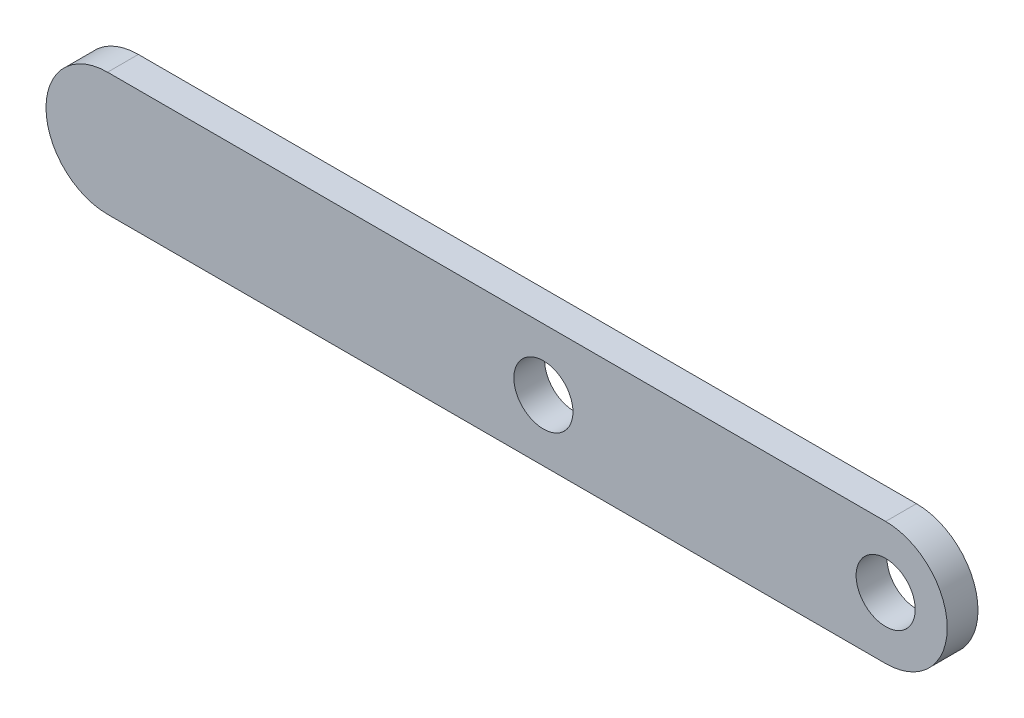
from build123d import *

# Parameters (mm, degrees)
SKETCH1_R           = 3.048
BOSS_EXTRUDE1_DEPTH = 3.175


with BuildPart() as part:
    # Sketch1 → Boss-Extrude1 (new body)
    with BuildSketch(Plane.XY):
        with BuildLine():
            Line((-40.132, -6.35), (40.132, -6.35))
            ThreePointArc((40.132, -6.35), (46.482, 0), (40.132, 6.35))
            Line((40.132, 6.35), (-40.132, 6.35))
            ThreePointArc((-40.132, 6.35), (-46.482, 0), (-40.132, -6.35))
        make_face()
        with Locations((40.132, 0)):
            Circle(SKETCH1_R, mode=Mode.SUBTRACT)
        with Locations((4.826, 0)):
            Circle(SKETCH1_R, mode=Mode.SUBTRACT)
    extrude(amount=BOSS_EXTRUDE1_DEPTH)


solid = part.part
